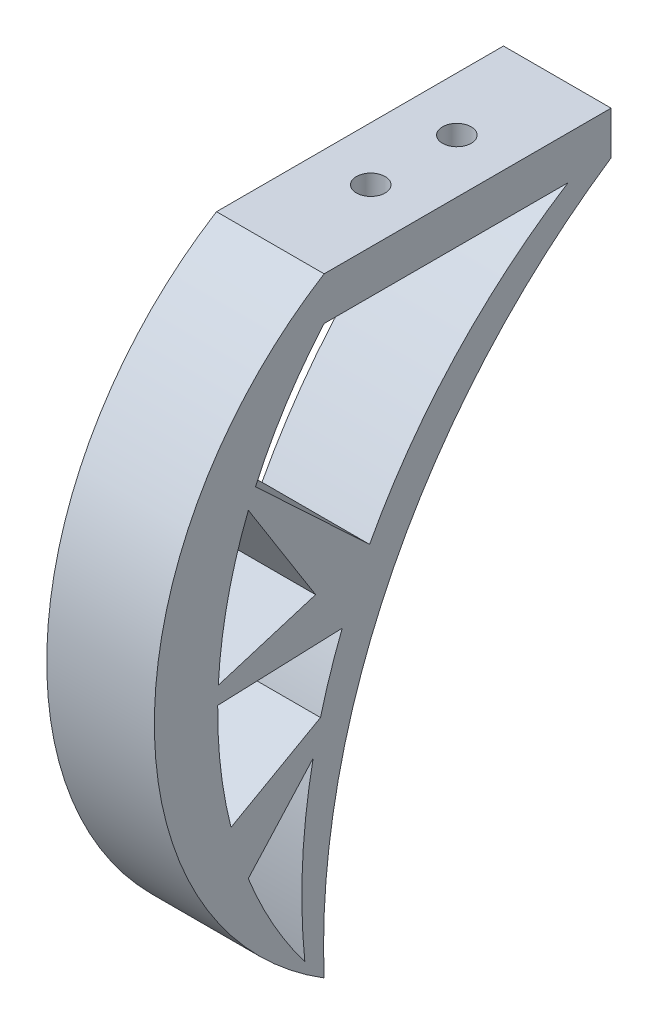
from build123d import *

# Parameters (mm, degrees)
SKETCH1_W            = 15
SKETCH1_H            = 40
BOSS_EXTRUDE1_DEPTH  = 6
BOSS_EXTRUDE3_DEPTH  = 15
BOSS_EXTRUDE7_DEPTH  = 15
BOSS_EXTRUDE9_DEPTH  = 15
BOSS_EXTRUDE10_DEPTH = 15
BOSS_EXTRUDE11_DEPTH = 15
CUT_EXTRUDE2_REACH   = 87
SKETCH11_R           = 2


with BuildPart() as part:
    # Sketch1 → Boss-Extrude1 (new body)
    with BuildSketch(Plane(origin=(0, 0, 0), x_dir=(1, 0, 0), z_dir=(0, 1, 0))):
        with Locations((7.5, 20)):
            Rectangle(SKETCH1_W, SKETCH1_H)
    extrude(amount=BOSS_EXTRUDE1_DEPTH)

    # Sketch2 → Boss-Extrude3 (add)
    with BuildSketch(Plane.ZY):
        with BuildLine():
            Line((0, 0), (0, 6))
            ThreePointArc((0, 6), (23.660865618, -36.5), (0, -79))
            ThreePointArc((0, -79), (14.836408469, -39.5), (0, 0))
        make_face()
    extrude(amount=-BOSS_EXTRUDE3_DEPTH)

    # Sketch4 → Boss-Extrude7 (add)
    with BuildSketch(Plane.ZY):
        with BuildLine():
            ThreePointArc((2.687694394, -75.697436861), (-4.903747344, -32.637432794), (-34, 0))
            Line((-34, 0), (-40, 0))
            ThreePointArc((-40, 0), (-9.691402152, -34.280456786), (0, -79))
            ThreePointArc((0, -79), (1.37315296, -77.372568069), (2.687694394, -75.697436861))
        make_face()
    extrude(amount=-BOSS_EXTRUDE7_DEPTH)

    # Sketch6 → Boss-Extrude9 (add)
    with BuildSketch(Plane(origin=(15, 0, 0), x_dir=(0, 0, -1), z_dir=(1, 0, 0))):
        with BuildLine():
            Line((-23.598326506, -39), (6.336124845, -29.82478781))
            ThreePointArc((6.336124845, -29.82478781), (7.039786657, -35.139310612), (2.528857435, -38.036000122))
            Line((2.528857435, -38.036000122), (-23.598326506, -39))
        make_face()
    extrude(amount=-BOSS_EXTRUDE9_DEPTH)

    # Sketch7 → Boss-Extrude10 (add)
    with BuildSketch(Plane(origin=(15, 0, 0), x_dir=(0, 0, -1), z_dir=(1, 0, 0))):
        Polygon((-12.974883891, -54.329621557), (5.491788936, -43.926999792), (-14.212166694, -65.750503945), align=None)
    extrude(amount=-BOSS_EXTRUDE10_DEPTH)

    # Sketch8 → Boss-Extrude11 (add)
    with BuildSketch(Plane(origin=(15, 0, 0), x_dir=(0, 0, -1), z_dir=(1, 0, 0))):
        Polygon((-15.593532308, -9.266721382), (6.336124845, -29.82478781), (2.528857435, -38.036000122), align=None)
    extrude(amount=-BOSS_EXTRUDE11_DEPTH)

    # Sketch11 → Cut-Extrude2 (cut, up to next)
    with BuildSketch(Plane(origin=(0, 6, 0), x_dir=(1, 0, 0), z_dir=(0, 1, 0)), mode=Mode.PRIVATE) as cut_extrude2_sk1:
        with Locations((7.5, 26)):
            Circle(SKETCH11_R)
    cut_extrude2_tool1 = extrude(cut_extrude2_sk1.sketch, amount=-CUT_EXTRUDE2_REACH, mode=Mode.PRIVATE) & part.part
    add(cut_extrude2_tool1.solids().sort_by_distance((7.5, 6, -26))[0], mode=Mode.SUBTRACT)
    # Sketch11 → Cut-Extrude2 (cut, up to next)
    with BuildSketch(Plane(origin=(0, 6, 0), x_dir=(1, 0, 0), z_dir=(0, 1, 0)), mode=Mode.PRIVATE) as cut_extrude2_sk2:
        with Locations((7.5, 14)):
            Circle(SKETCH11_R)
    cut_extrude2_tool2 = extrude(cut_extrude2_sk2.sketch, amount=-CUT_EXTRUDE2_REACH, mode=Mode.PRIVATE) & part.part
    add(cut_extrude2_tool2.solids().sort_by_distance((7.5, 6, -14))[0], mode=Mode.SUBTRACT)


solid = part.part
